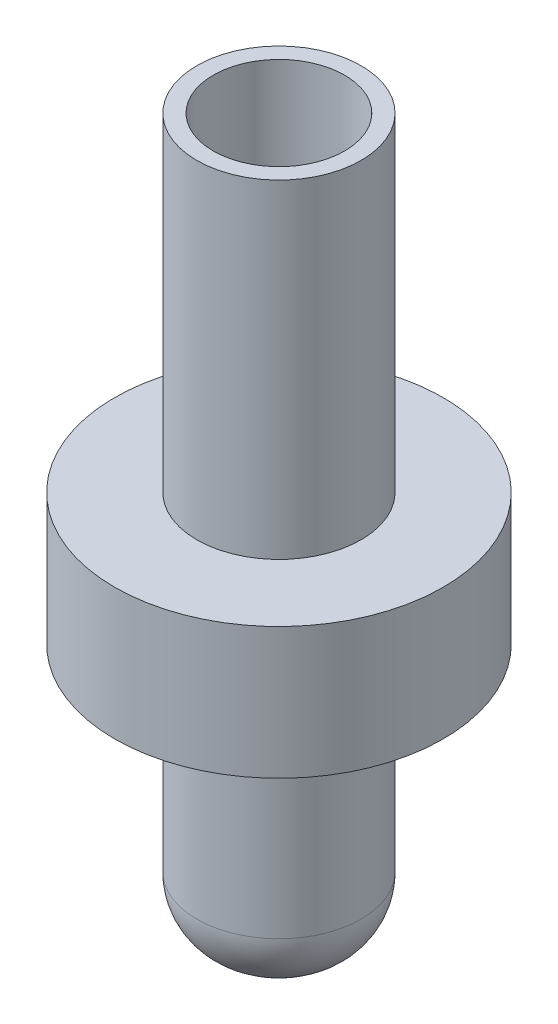
from build123d import *

# Parameters (mm, degrees)
SKETCH1_R           = 1.25
BOSS_EXTRUDE1_DEPTH = 4
SKETCH2_R           = 2.5
BOSS_EXTRUDE2_DEPTH = 2
SKETCH3_R           = 1.25
SKETCH3_R_2         = 1
BOSS_EXTRUDE3_DEPTH = 5
FILLET1_R           = 1


with BuildPart() as part:
    # Sketch1 → Boss-Extrude1 (new body)
    with BuildSketch(Plane(origin=(0, 0, 0), x_dir=(1, 0, 0), z_dir=(0, 1, 0))):
        Circle(SKETCH1_R)
    extrude(amount=BOSS_EXTRUDE1_DEPTH)

    # Sketch2 → Boss-Extrude2 (add)
    with BuildSketch(Plane(origin=(0, 4, 0), x_dir=(1, 0, 0), z_dir=(0, 1, 0))):
        Circle(SKETCH2_R)
    extrude(amount=BOSS_EXTRUDE2_DEPTH)

    # Sketch3 → Boss-Extrude3 (add)
    with BuildSketch(Plane(origin=(0, 6, 0), x_dir=(1, 0, 0), z_dir=(0, 1, 0))):
        Circle(SKETCH3_R)
        Circle(SKETCH3_R_2, mode=Mode.SUBTRACT)
    extrude(amount=BOSS_EXTRUDE3_DEPTH)

    # Fillet1
    fillet1_edges = [part.edges().sort_by_distance(p)[0] for p in [
        (-1.25, 0, 0),
    ]]
    fillet(fillet1_edges, radius=FILLET1_R)


solid = part.part
